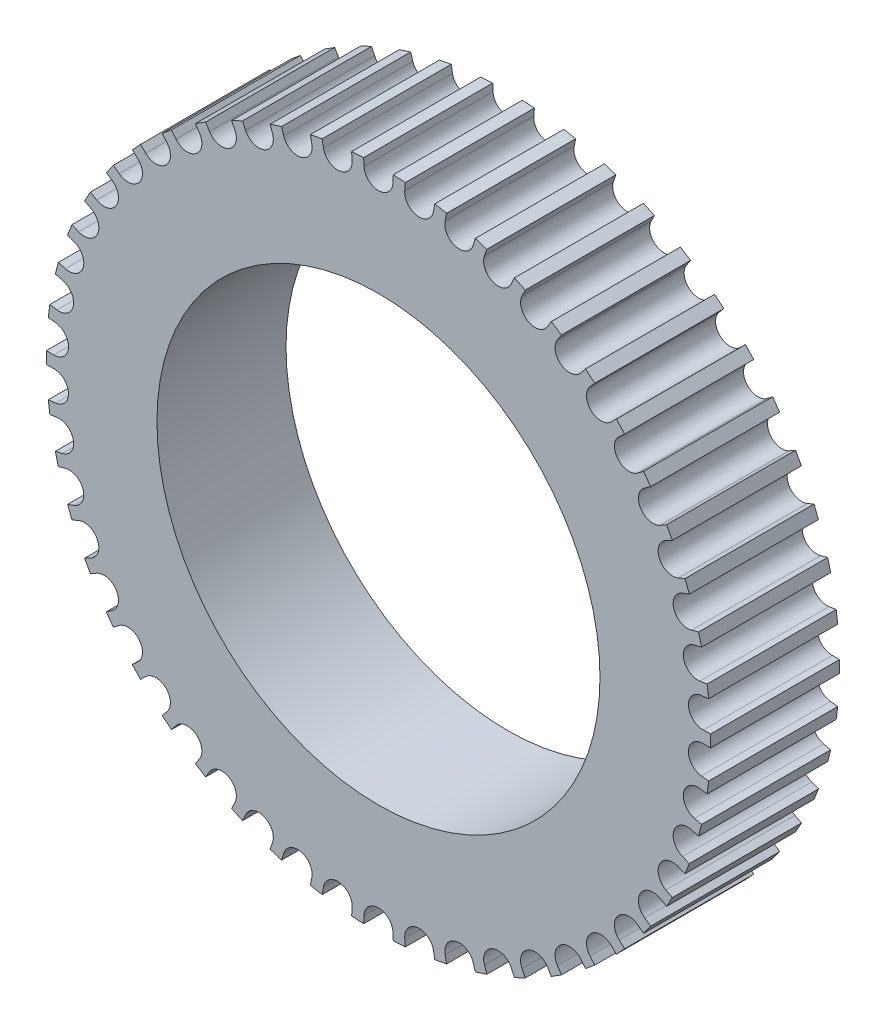
from build123d import *

# Parameters (mm, degrees)
BOSS_EXTRUDE1_DEPTH     = 6
SKETCH3_R               = 7.5
BOSS_EXTRUDE2_DEPTH     = 5
SKETCH4_R               = 2.55
CUT_EXTRUDE1_DEPTH      = 12
SKETCH6_R               = 1.25
CUT_EXTRUDE2_DEPTH      = 16.435479291
CUT_EXTRUDE2_DEPTH_BACK = 16.435479291
SKETCH8_R               = 10.297646543
CUT_EXTRUDE4_DEPTH      = 12.0000001


with BuildPart() as part:
    # Sketch1 → Boss-Extrude1 (new body)
    with BuildSketch(Plane.XY):
        with BuildLine():
            Line((-0.67435755, -15.083586393), (-0.689160931, -15.422639574))
            Line((-0.689160931, -15.422639574), (-1.249242597, -15.387402223))
            Line((-1.249242597, -15.387402223), (-1.221434618, -15.049167222))
            ThreePointArc((-1.221434618, -15.049167222), (-1.809564921, -14.324181305), (-2.559514695, -14.880128397))
            Line((-2.559514695, -14.880128397), (-2.616695979, -15.214652687))
            Line((-2.616695979, -15.214652687), (-3.167944822, -15.109496346))
            Line((-3.167944822, -15.109496346), (-3.097964031, -14.777413693))
            ThreePointArc((-3.097964031, -14.777413693), (-3.590591922, -13.984432234), (-4.404306765, -14.442001887))
            Line((-4.404306765, -14.442001887), (-4.502964169, -14.766721637))
            Line((-4.502964169, -14.766721637), (-5.036686666, -14.593304686))
            Line((-5.036686666, -14.593304686), (-4.925636701, -14.272611523))
            ThreePointArc((-4.925636701, -14.272611523), (-5.314993144, -13.424140313), (-6.179640287, -13.77611638))
            Line((-6.179640287, -13.77611638), (-6.318217923, -14.085910567))
            Line((-6.318217923, -14.085910567), (-6.825996952, -13.846967893))
            Line((-6.825996952, -13.846967893), (-6.675629138, -13.542721743))
            ThreePointArc((-6.675629138, -13.542721743), (-6.955573749, -12.65214168), (-7.857517189, -12.892973288))
            Line((-7.857517189, -12.892973288), (-8.033829607, -13.182956272))
            Line((-8.033829607, -13.182956272), (-8.507657188, -12.882256145))
            Line((-8.507657188, -12.882256145), (-8.320342916, -12.599255151))
            ThreePointArc((-8.320342916, -12.599255151), (-8.4864608, -11.680611215), (-9.411476352, -11.806500306))
            Line((-9.411476352, -11.806500306), (-9.622742998, -12.072098882))
            Line((-9.622742998, -12.072098882), (-10.055146588, -11.714383522))
            Line((-10.055146588, -11.714383522), (-9.833839915, -11.457090779))
            ThreePointArc((-9.833839915, -11.457090779), (-9.883511296, -10.524870533), (-10.81701091, -10.533831761))
            Line((-10.81701091, -10.533831761), (-11.059899984, -10.770857281))
            Line((-11.059899984, -10.770857281), (-11.44406032, -10.361768074))
            Line((-11.44406032, -10.361768074), (-11.192251385, -10.134241241))
            ThreePointArc((-11.192251385, -10.134241241), (-11.124692914, -9.203146355), (-12.051954744, -9.095038396))
            Line((-12.051954744, -9.095038396), (-12.322635741, -9.299752826))
            Line((-12.322635741, -9.299752826), (-12.652494384, -8.845741352))
            Line((-12.652494384, -8.845741352), (-12.374154364, -8.651568665))
            ThreePointArc((-12.374154364, -8.651568665), (-12.190431479, -7.736283062), (-13.096832053, -7.512810843))
            Line((-13.096832053, -7.512810843), (-13.39103617, -7.681985714))
            Line((-13.39103617, -7.681985714), (-13.661391054, -7.190212006))
            Line((-13.661391054, -7.190212006), (-13.360909537, -7.032455683))
            ThreePointArc((-13.360909537, -7.032455683), (-13.063919658, -6.147413964), (-13.935164497, -5.812101775))
            Line((-13.935164497, -5.812101775), (-14.24825196, -5.943069098))
            Line((-14.24825196, -5.943069098), (-14.454839426, -5.421288721))
            Line((-14.454839426, -5.421288721), (-14.136955185, -5.302436674))
            ThreePointArc((-14.136955185, -5.302436674), (-13.731382019, -4.461596475), (-14.553731072, -4.01973239))
            Line((-14.553731072, -4.01973239), (-14.880764305, -4.110426732))
            Line((-14.880764305, -4.110426732), (-15.020326345, -3.566868474))
            Line((-15.020326345, -3.566868474), (-14.690052605, -3.48879507))
            ThreePointArc((-14.690052605, -3.48879507), (-14.182292284, -2.705416944), (-14.942776614, -2.163969424))
            Line((-14.942776614, -2.163969424), (-15.278598107, -2.212960481))
            Line((-15.278598107, -2.212960481), (-15.348933745, -1.656196581))
            Line((-15.348933745, -1.656196581), (-15.01147912, -1.620133085))
            ThreePointArc((-15.01147912, -1.620133085), (-14.409539327, -0.906571372), (-15.096165642, -0.274079367))
            Line((-15.096165642, -0.274079367), (-15.435479291, -0.280594522))
            Line((-15.435479291, -0.280594522), (-15.435479291, 0.280594522))
            Line((-15.435479291, 0.280594522), (-15.096165642, 0.274079367))
            ThreePointArc((-15.096165642, 0.274079367), (-14.409539327, 0.906571372), (-15.01147912, 1.620133085))
            Line((-15.01147912, 1.620133085), (-15.348933745, 1.656196581))
            Line((-15.348933745, 1.656196581), (-15.278598107, 2.212960481))
            Line((-15.278598107, 2.212960481), (-14.942776614, 2.163969424))
            ThreePointArc((-14.942776614, 2.163969424), (-14.182292284, 2.705416944), (-14.690052605, 3.48879507))
            Line((-14.690052605, 3.48879507), (-15.020326345, 3.566868474))
            Line((-15.020326345, 3.566868474), (-14.880764305, 4.110426732))
            Line((-14.880764305, 4.110426732), (-14.553731072, 4.01973239))
            ThreePointArc((-14.553731072, 4.01973239), (-13.731382019, 4.461596475), (-14.136955185, 5.302436674))
            Line((-14.136955185, 5.302436674), (-14.454839426, 5.421288721))
            Line((-14.454839426, 5.421288721), (-14.24825196, 5.943069098))
            Line((-14.24825196, 5.943069098), (-13.935164497, 5.812101775))
            ThreePointArc((-13.935164497, 5.812101775), (-13.063919658, 6.147413964), (-13.360909537, 7.032455683))
            Line((-13.360909537, 7.032455683), (-13.661391054, 7.190212006))
            Line((-13.661391054, 7.190212006), (-13.39103617, 7.681985714))
            Line((-13.39103617, 7.681985714), (-13.096832053, 7.512810843))
            ThreePointArc((-13.096832053, 7.512810843), (-12.190431479, 7.736283062), (-12.374154364, 8.651568665))
            Line((-12.374154364, 8.651568665), (-12.652494384, 8.845741352))
            Line((-12.652494384, 8.845741352), (-12.322635741, 9.299752826))
            Line((-12.322635741, 9.299752826), (-12.051954744, 9.095038396))
            ThreePointArc((-12.051954744, 9.095038396), (-11.124692914, 9.203146355), (-11.192251385, 10.134241241))
            Line((-11.192251385, 10.134241241), (-11.44406032, 10.361768074))
            Line((-11.44406032, 10.361768074), (-11.059899984, 10.770857281))
            Line((-11.059899984, 10.770857281), (-10.81701091, 10.533831761))
            ThreePointArc((-10.81701091, 10.533831761), (-9.883511296, 10.524870533), (-9.833839915, 11.457090779))
            Line((-9.833839915, 11.457090779), (-10.055146588, 11.714383522))
            Line((-10.055146588, 11.714383522), (-9.622742998, 12.072098882))
            Line((-9.622742998, 12.072098882), (-9.411476352, 11.806500306))
            ThreePointArc((-9.411476352, 11.806500306), (-8.4864608, 11.680611215), (-8.320342916, 12.599255151))
            Line((-8.320342916, 12.599255151), (-8.507657188, 12.882256145))
            Line((-8.507657188, 12.882256145), (-8.033829607, 13.182956272))
            Line((-8.033829607, 13.182956272), (-7.857517189, 12.892973288))
            ThreePointArc((-7.857517189, 12.892973288), (-6.955573749, 12.65214168), (-6.675629138, 13.542721743))
            Line((-6.675629138, 13.542721743), (-6.825996952, 13.846967893))
            Line((-6.825996952, 13.846967893), (-6.318217923, 14.085910567))
            Line((-6.318217923, 14.085910567), (-6.179640287, 13.77611638))
            ThreePointArc((-6.179640287, 13.77611638), (-5.314993144, 13.424140313), (-4.925636701, 14.272611523))
            Line((-4.925636701, 14.272611523), (-5.036686666, 14.593304686))
            Line((-5.036686666, 14.593304686), (-4.502964169, 14.766721637))
            Line((-4.502964169, 14.766721637), (-4.404306765, 14.442001887))
            ThreePointArc((-4.404306765, 14.442001887), (-3.590591922, 13.984432234), (-3.097964031, 14.777413693))
            Line((-3.097964031, 14.777413693), (-3.167944822, 15.109496346))
            Line((-3.167944822, 15.109496346), (-2.616695979, 15.214652687))
            Line((-2.616695979, 15.214652687), (-2.559514695, 14.880128397))
            ThreePointArc((-2.559514695, 14.880128397), (-1.809564921, 14.324181305), (-1.221434618, 15.049167222))
            Line((-1.221434618, 15.049167222), (-1.249242597, 15.387402223))
            Line((-1.249242597, 15.387402223), (-0.689160931, 15.422639574))
            Line((-0.689160931, 15.422639574), (-0.67435755, 15.083586393))
            ThreePointArc((-0.67435755, 15.083586393), (0, 14.43802948), (0.67435755, 15.083586393))
            Line((0.67435755, 15.083586393), (0.689160931, 15.422639574))
            Line((0.689160931, 15.422639574), (1.249242597, 15.387402223))
            Line((1.249242597, 15.387402223), (1.221434618, 15.049167222))
            ThreePointArc((1.221434618, 15.049167222), (1.809564921, 14.324181305), (2.559514695, 14.880128397))
            Line((2.559514695, 14.880128397), (2.616695979, 15.214652687))
            Line((2.616695979, 15.214652687), (3.167944822, 15.109496346))
            Line((3.167944822, 15.109496346), (3.097964031, 14.777413693))
            ThreePointArc((3.097964031, 14.777413693), (3.590591922, 13.984432234), (4.404306765, 14.442001887))
            Line((4.404306765, 14.442001887), (4.502964169, 14.766721637))
            Line((4.502964169, 14.766721637), (5.036686666, 14.593304686))
            Line((5.036686666, 14.593304686), (4.925636701, 14.272611523))
            ThreePointArc((4.925636701, 14.272611523), (5.314993144, 13.424140313), (6.179640287, 13.77611638))
            Line((6.179640287, 13.77611638), (6.318217923, 14.085910567))
            Line((6.318217923, 14.085910567), (6.825996952, 13.846967893))
            Line((6.825996952, 13.846967893), (6.675629138, 13.542721743))
            ThreePointArc((6.675629138, 13.542721743), (6.955573749, 12.65214168), (7.857517189, 12.892973288))
            Line((7.857517189, 12.892973288), (8.033829607, 13.182956272))
            Line((8.033829607, 13.182956272), (8.507657188, 12.882256145))
            Line((8.507657188, 12.882256145), (8.320342916, 12.599255151))
            ThreePointArc((8.320342916, 12.599255151), (8.4864608, 11.680611215), (9.411476352, 11.806500306))
            Line((9.411476352, 11.806500306), (9.622742998, 12.072098882))
            Line((9.622742998, 12.072098882), (10.055146588, 11.714383522))
            Line((10.055146588, 11.714383522), (9.833839915, 11.457090779))
            ThreePointArc((9.833839915, 11.457090779), (9.883511296, 10.524870533), (10.81701091, 10.533831761))
            Line((10.81701091, 10.533831761), (11.059899984, 10.770857281))
            Line((11.059899984, 10.770857281), (11.44406032, 10.361768074))
            Line((11.44406032, 10.361768074), (11.192251385, 10.134241241))
            ThreePointArc((11.192251385, 10.134241241), (11.124692914, 9.203146355), (12.051954744, 9.095038396))
            Line((12.051954744, 9.095038396), (12.322635741, 9.299752826))
            Line((12.322635741, 9.299752826), (12.652494384, 8.845741352))
            Line((12.652494384, 8.845741352), (12.374154364, 8.651568665))
            ThreePointArc((12.374154364, 8.651568665), (12.190431479, 7.736283062), (13.096832053, 7.512810843))
            Line((13.096832053, 7.512810843), (13.39103617, 7.681985714))
            Line((13.39103617, 7.681985714), (13.661391054, 7.190212006))
            Line((13.661391054, 7.190212006), (13.360909537, 7.032455683))
            ThreePointArc((13.360909537, 7.032455683), (13.063919658, 6.147413964), (13.935164497, 5.812101775))
            Line((13.935164497, 5.812101775), (14.24825196, 5.943069098))
            Line((14.24825196, 5.943069098), (14.454839426, 5.421288721))
            Line((14.454839426, 5.421288721), (14.136955185, 5.302436674))
            ThreePointArc((14.136955185, 5.302436674), (13.731382019, 4.461596475), (14.553731072, 4.01973239))
            Line((14.553731072, 4.01973239), (14.880764305, 4.110426732))
            Line((14.880764305, 4.110426732), (15.020326345, 3.566868474))
            Line((15.020326345, 3.566868474), (14.690052605, 3.48879507))
            ThreePointArc((14.690052605, 3.48879507), (14.182292284, 2.705416944), (14.942776614, 2.163969424))
            Line((14.942776614, 2.163969424), (15.278598107, 2.212960481))
            Line((15.278598107, 2.212960481), (15.348933745, 1.656196581))
            Line((15.348933745, 1.656196581), (15.01147912, 1.620133085))
            ThreePointArc((15.01147912, 1.620133085), (14.409539327, 0.906571372), (15.096165642, 0.274079367))
            Line((15.096165642, 0.274079367), (15.435479291, 0.280594522))
            Line((15.435479291, 0.280594522), (15.435479291, -0.280594522))
            Line((15.435479291, -0.280594522), (15.096165642, -0.274079367))
            ThreePointArc((15.096165642, -0.274079367), (14.409539327, -0.906571372), (15.01147912, -1.620133085))
            Line((15.01147912, -1.620133085), (15.348933745, -1.656196581))
            Line((15.348933745, -1.656196581), (15.278598107, -2.212960481))
            Line((15.278598107, -2.212960481), (14.942776614, -2.163969424))
            ThreePointArc((14.942776614, -2.163969424), (14.182292284, -2.705416944), (14.690052605, -3.48879507))
            Line((14.690052605, -3.48879507), (15.020326345, -3.566868474))
            Line((15.020326345, -3.566868474), (14.880764305, -4.110426732))
            Line((14.880764305, -4.110426732), (14.553731072, -4.01973239))
            ThreePointArc((14.553731072, -4.01973239), (13.731382019, -4.461596475), (14.136955185, -5.302436674))
            Line((14.136955185, -5.302436674), (14.454839426, -5.421288721))
            Line((14.454839426, -5.421288721), (14.24825196, -5.943069098))
            Line((14.24825196, -5.943069098), (13.935164497, -5.812101775))
            ThreePointArc((13.935164497, -5.812101775), (13.063919658, -6.147413964), (13.360909537, -7.032455683))
            Line((13.360909537, -7.032455683), (13.661391054, -7.190212006))
            Line((13.661391054, -7.190212006), (13.39103617, -7.681985714))
            Line((13.39103617, -7.681985714), (13.096832053, -7.512810843))
            ThreePointArc((13.096832053, -7.512810843), (12.190431479, -7.736283062), (12.374154364, -8.651568665))
            Line((12.374154364, -8.651568665), (12.652494384, -8.845741352))
            Line((12.652494384, -8.845741352), (12.322635741, -9.299752826))
            Line((12.322635741, -9.299752826), (12.051954744, -9.095038396))
            ThreePointArc((12.051954744, -9.095038396), (11.124692914, -9.203146355), (11.192251385, -10.134241241))
            Line((11.192251385, -10.134241241), (11.44406032, -10.361768074))
            Line((11.44406032, -10.361768074), (11.059899984, -10.770857281))
            Line((11.059899984, -10.770857281), (10.81701091, -10.533831761))
            ThreePointArc((10.81701091, -10.533831761), (9.883511296, -10.524870533), (9.833839915, -11.457090779))
            Line((9.833839915, -11.457090779), (10.055146588, -11.714383522))
            Line((10.055146588, -11.714383522), (9.622742998, -12.072098882))
            Line((9.622742998, -12.072098882), (9.411476352, -11.806500306))
            ThreePointArc((9.411476352, -11.806500306), (8.4864608, -11.680611215), (8.320342916, -12.599255151))
            Line((8.320342916, -12.599255151), (8.507657188, -12.882256145))
            Line((8.507657188, -12.882256145), (8.033829607, -13.182956272))
            Line((8.033829607, -13.182956272), (7.857517189, -12.892973288))
            ThreePointArc((7.857517189, -12.892973288), (6.955573749, -12.65214168), (6.675629138, -13.542721743))
            Line((6.675629138, -13.542721743), (6.825996952, -13.846967893))
            Line((6.825996952, -13.846967893), (6.318217923, -14.085910567))
            Line((6.318217923, -14.085910567), (6.179640287, -13.77611638))
            ThreePointArc((6.179640287, -13.77611638), (5.314993144, -13.424140313), (4.925636701, -14.272611523))
            Line((4.925636701, -14.272611523), (5.036686666, -14.593304686))
            Line((5.036686666, -14.593304686), (4.502964169, -14.766721637))
            Line((4.502964169, -14.766721637), (4.404306765, -14.442001887))
            ThreePointArc((4.404306765, -14.442001887), (3.590591922, -13.984432234), (3.097964031, -14.777413693))
            Line((3.097964031, -14.777413693), (3.167944822, -15.109496346))
            Line((3.167944822, -15.109496346), (2.616695979, -15.214652687))
            Line((2.616695979, -15.214652687), (2.559514695, -14.880128397))
            ThreePointArc((2.559514695, -14.880128397), (1.809564921, -14.324181305), (1.221434618, -15.049167222))
            Line((1.221434618, -15.049167222), (1.249242597, -15.387402223))
            Line((1.249242597, -15.387402223), (0.689160931, -15.422639574))
            Line((0.689160931, -15.422639574), (0.67435755, -15.083586393))
            ThreePointArc((0.67435755, -15.083586393), (0, -14.43802948), (-0.67435755, -15.083586393))
        make_face()
    extrude(amount=BOSS_EXTRUDE1_DEPTH)

    # Sketch3 → Boss-Extrude2 (add)
    with BuildSketch(Plane(origin=(0, 0, 0), x_dir=(-1, 0, 0), z_dir=(0, 0, -1))):
        Circle(SKETCH3_R)
    extrude(amount=BOSS_EXTRUDE2_DEPTH)

    # Sketch4 → Cut-Extrude1 (cut, through all)
    with BuildSketch(Plane(origin=(0, 0, -5), x_dir=(-1, 0, 0), z_dir=(0, 0, -1))):
        Circle(SKETCH4_R)
    extrude(amount=-CUT_EXTRUDE1_DEPTH, mode=Mode.SUBTRACT)

    # Sketch6 → Cut-Extrude2 (cut, two sides)
    with BuildSketch(Plane(origin=(0, 0, 0), x_dir=(0, 0, -1), z_dir=(1, 0, 0))) as cut_extrude2_sk:
        with Locations((2.5, 0)):
            Circle(SKETCH6_R)
    extrude(amount=CUT_EXTRUDE2_DEPTH, mode=Mode.SUBTRACT)
    extrude(cut_extrude2_sk.sketch, amount=-CUT_EXTRUDE2_DEPTH_BACK, mode=Mode.SUBTRACT)

    # Sketch8 → Cut-Extrude4 (cut, through all)
    with BuildSketch(Plane(origin=(0, 0, -5), x_dir=(-1, 0, 0), z_dir=(0, 0, -1))):
        Circle(SKETCH8_R)
    extrude(amount=-CUT_EXTRUDE4_DEPTH, mode=Mode.SUBTRACT)


solid = part.part
